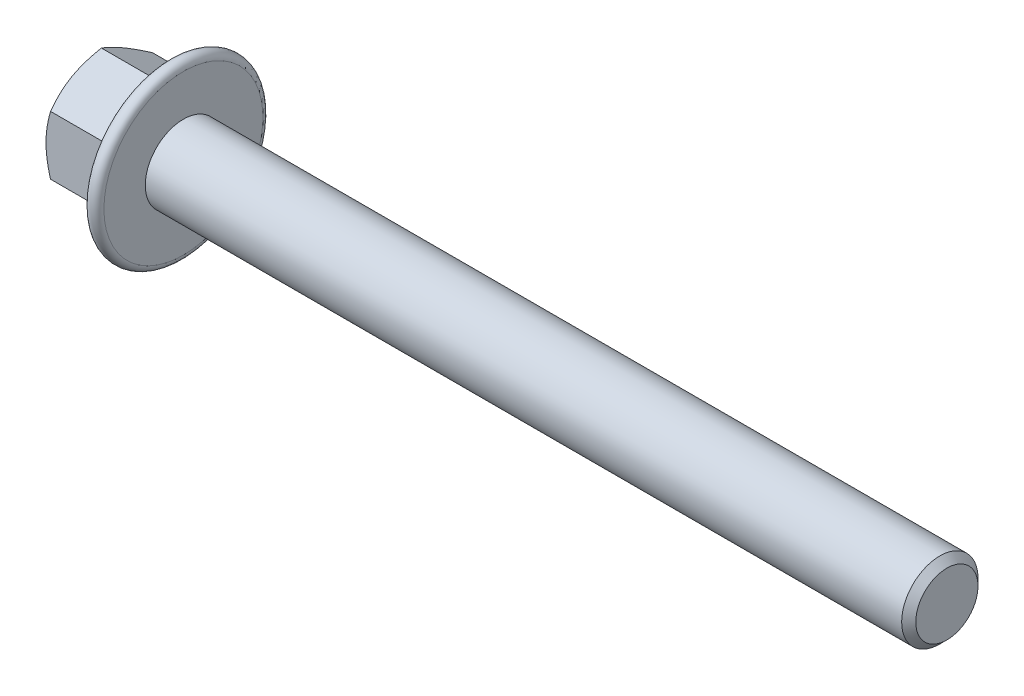
from build123d import *

# Parameters (mm, degrees)
BASEHEAD_DEPTH    = 6.8
FLANGEHEXFILLET_R = 0.11


with BuildPart() as part:
    # Sketch1 → BaseHead (new body)
    with BuildSketch(Plane(origin=(0, 0, 0), x_dir=(0, 0, -1), z_dir=(1, 0, 0))):
        Polygon((4, 2.309401077), (4, -2.309401077), (0, -4.618802154), (-4, -2.309401077), (-4, 2.309401077), (0, 4.618802154), align=None)
    extrude(amount=BASEHEAD_DEPTH)

    # BodySke → BaseBody (revolve)
    with BuildSketch(Plane.XY, mode=Mode.PRIVATE) as basebody_sk:
        Polygon((0, 0), (66.8, 0), (66.8, 2.4455), (66.2455, 3), (0, 3), align=None)
    revolve(basebody_sk.sketch.rotate(Axis((0, 0, 0), (1, 0, 0)), 90), axis=Axis((0, 0, 0), (1, 0, 0)))  # turned: the seam where the file's is

    # Sketch3 → HeadChamfer (revolve, cut)
    with BuildSketch(Plane.XY, mode=Mode.PRIVATE) as headchamfer_sk:
        Polygon((0, 4), (3.244016936, 9.618802154), (3.244016936, 14.618802154), (-10, 14.618802154), (-10, 4), align=None)
    revolve(headchamfer_sk.sketch.rotate(Axis((0, 0, 0), (1, 0, 0)), 90), axis=Axis((0, 0, 0), (1, 0, 0)), mode=Mode.SUBTRACT)  # turned: the seam where the file's is

    # Sketch4 → Flange (revolve)
    with BuildSketch(Plane.XY, mode=Mode.PRIVATE) as flange_sk:
        with BuildLine():
            Line((3.389888261, 0), (5.733169059, 6.438111079))
            ThreePointArc((5.733169059, 6.438111079), (6.345506498, 6.791644264), (6.8, 6.25))
            Line((6.8, 6.25), (6.8, 0))
            Line((6.8, 0), (3.389888261, 0))
        make_face()
    revolve(flange_sk.sketch.rotate(Axis((0, 0, 0), (1, 0, 0)), 90), axis=Axis((0, 0, 0), (1, 0, 0)))  # turned: the seam where the file's is

    # FlangeHexFillet
    flangehexfillet_edges = [part.edges().sort_by_distance(p)[0] for p in [
        (4.845769198, 0, -4),
        (4.845769198, -3.464101615, -2),
        (4.905726696, 1.159737717, 4),
        (4.845769198, 3.464101615, 2),
        (4.845769198, 3.464101615, -2),
        (4.845769198, -3.464101615, 2),
        (4.905726696, -1.159737717, 4),
    ]]
    fillet(flangehexfillet_edges, radius=FLANGEHEXFILLET_R)


solid = part.part
